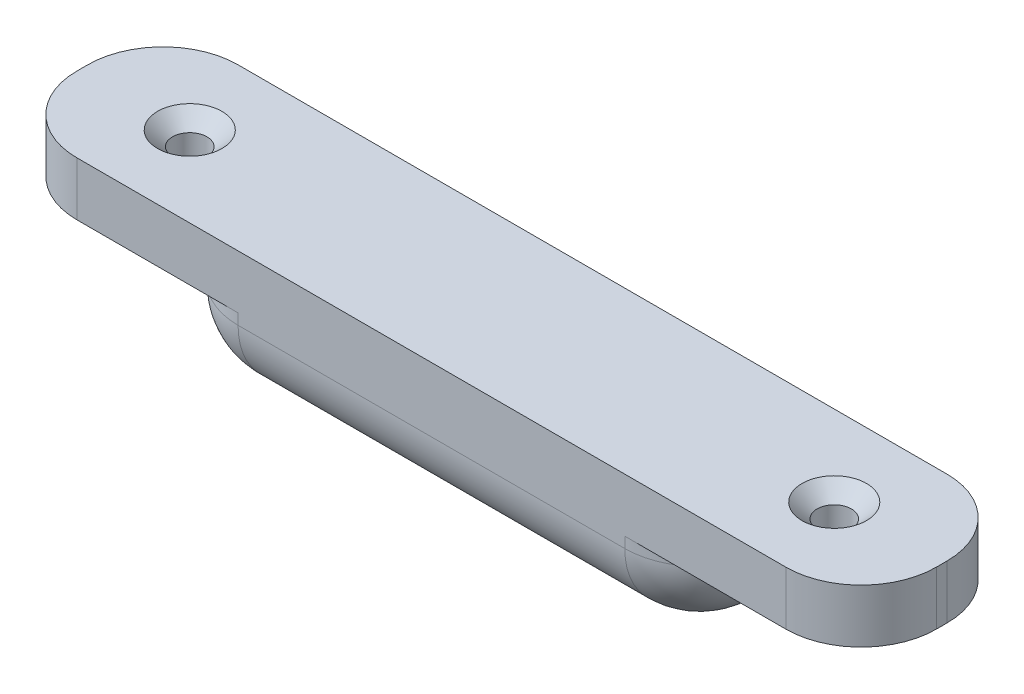
from build123d import *

# Parameters (mm, degrees)
BOSS_EXTRU_1_DEPTH                                 = 15
FRAISAGE_POUR_VIS_T_TE_FRAIS_E_CRUCIFO_D           = 3.2
FRAISAGE_POUR_VIS_T_TE_FRAIS_E_CRUCIFO_CSINK_D     = 6
FRAISAGE_POUR_VIS_T_TE_FRAIS_E_CRUCIFO_CSINK_ANGLE = 92
CONG_1_R                                           = 7


with BuildPart() as part:
    # Esquisse1 → Boss.-Extru.1 (new body)
    with BuildSketch(Plane.XY):
        Polygon((0, 13), (-40, 13), (-40, 8), (-25, 8), (-25, 0), (0, 0), align=None)
        Polygon((40, 13), (0, 13), (0, 0), (25, 0), (25, 8), (40, 8), align=None)
    extrude(amount=BOSS_EXTRU_1_DEPTH)

    # Fraisage pour vis à tête fraisée cruciforme M31 (through all)
    with Locations(Plane(origin=(0, 13, 0), x_dir=(1, 0, 0), z_dir=(0, 1, 0))):
        with Locations((-30, -7.5), (30, -7.5)):
            CounterSinkHole(FRAISAGE_POUR_VIS_T_TE_FRAIS_E_CRUCIFO_D / 2, FRAISAGE_POUR_VIS_T_TE_FRAIS_E_CRUCIFO_CSINK_D / 2, counter_sink_angle=FRAISAGE_POUR_VIS_T_TE_FRAIS_E_CRUCIFO_CSINK_ANGLE)

    # Congé1
    cong_1_edges = [part.edges().sort_by_distance(p)[0] for p in [
        (40, 10.5, 0),
        (25, 4, 0),
        (0, 0, 0),
        (-25, 0, 7.5),
        (25, 0, 7.5),
        (40, 10.5, 15),
        (-40, 10.5, 15),
        (-25, 4, 15),
        (0, 0, 15),
        (-25, 4, 0),
        (25, 4, 15),
        (-40, 10.5, 0),
    ]]
    fillet(cong_1_edges, radius=CONG_1_R)


solid = part.part
